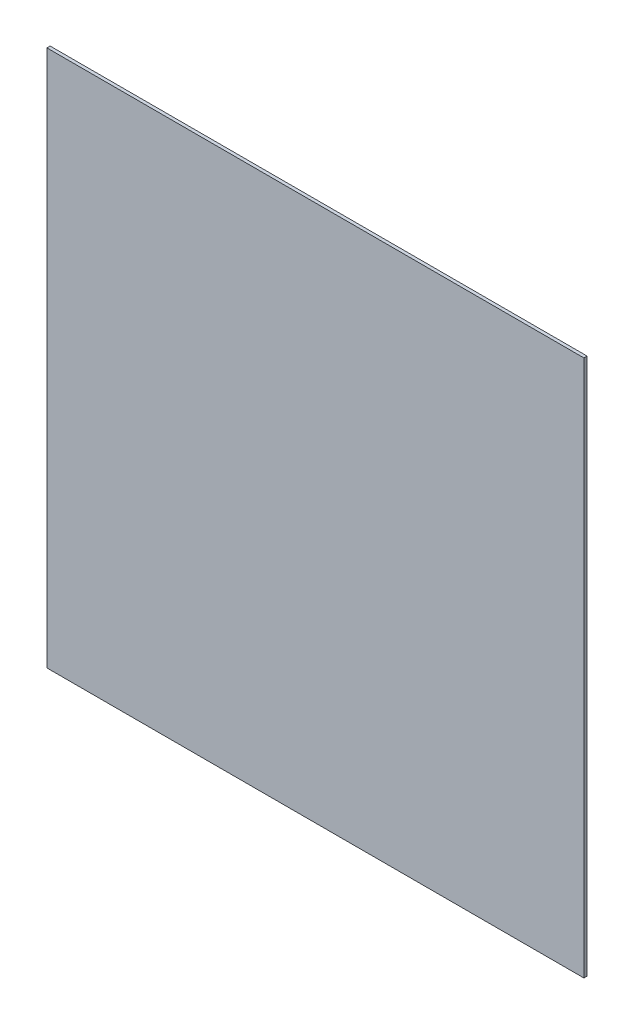
from build123d import *

# Parameters (mm, degrees)
ESBO_O1_W                = 1000
ESBO_O1_H                = 1000
RESSALTO_EXTRUS_O1_DEPTH = 3


with BuildPart() as part:
    # Esboço1 → Ressalto-extrusão1 (new body, symmetric)
    with BuildSketch(Plane.XY):
        Rectangle(ESBO_O1_W, ESBO_O1_H)
    extrude(amount=RESSALTO_EXTRUS_O1_DEPTH, both=True)


solid = part.part
